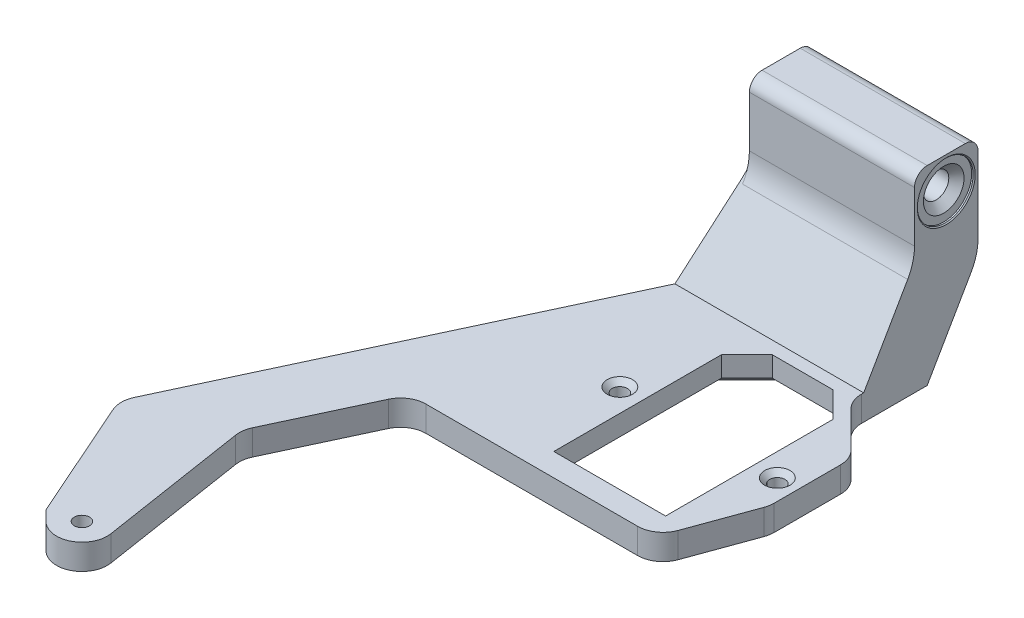
from build123d import *

# Parameters (mm, degrees)
SKETCH1_R           = 6.35
SKETCH1_R_2         = 1.905
BOSS_EXTRUDE1_DEPTH = 6.35
SKETCH2_W           = 41.275
SKETCH2_H           = 15.875
BOSS_EXTRUDE2_DEPTH = 41.275
SKETCH3_R           = 3.175
CUT_EXTRUDE1_DEPTH  = 92.391901083
SKETCH4_R           = 6.985
CUT_EXTRUDE2_DEPTH  = 0.635
CHAMFER1_SIZE       = 0.254
CHAMFER2_SIZE       = 1.905
FILLET3_R           = 3.175
CHAMFER3_SIZE       = 12.7
CHAMFER3_SIZE2      = 21.997045256
SKETCH6_R           = 1.905
CUT_EXTRUDE3_DEPTH  = 6.35
FILLET4_R           = 6.35
CHAMFER4_SIZE       = 1.27
CHAMFER5_SIZE       = 12.7
CHAMFER5_SIZE2      = 21.997045256
FILLET5_R           = 12.7
CHAMFER6_SIZE       = 1.27
SKETCH7_W           = 1.211538461
SKETCH7_H           = 0.583333334
CUT_EXTRUDE4_DEPTH  = 1.27


with BuildPart() as part:
    # Sketch1 → Boss-Extrude1 (new body)
    with BuildSketch(Plane(origin=(0, 0, 0), x_dir=(1, 0, 0), z_dir=(0, 1, 0))):
        with BuildLine():
            Line((-50.116901083, -123.351041208), (-35.638114305, -156.082441816))
            Line((-35.638114305, -156.082441816), (-33.084178049, -158.636378072))
            ThreePointArc((-33.084178049, -158.636378072), (-31.470087933, -148.484898058), (-22.319859515, -153.167968981))
            Line((-22.319859515, -153.167968981), (-28.38020679, -114.3))
            Line((-28.38020679, -114.3), (-15.055465459, -85.725))
            Line((-15.055465459, -85.725), (46.355, -85.725))
            Line((46.355, -85.725), (53.975, -64.789222064))
            Line((53.975, -64.789222064), (53.975, -44.45))
            Line((53.975, -44.45), (41.275, -31.75))
            Line((41.275, -31.75), (41.275, 0))
            Line((41.275, 0), (0, 0))
            Line((0, 0), (0, -15.875))
            Line((0, -15.875), (-50.116901083, -123.351041208))
        make_face()
        with Locations((-28.59405, -154.14625)):
            Circle(SKETCH1_R)
        with Locations((-28.59405, -154.14625)):
            Circle(SKETCH1_R_2, mode=Mode.SUBTRACT)
    extrude(amount=BOSS_EXTRUDE1_DEPTH)

    # Sketch2 → Boss-Extrude2 (add)
    with BuildSketch(Plane(origin=(0, 6.35, 0), x_dir=(1, 0, 0), z_dir=(0, 1, 0))):
        with Locations((20.6375, -7.9375)):
            Rectangle(SKETCH2_W, SKETCH2_H)
    extrude(amount=BOSS_EXTRUDE2_DEPTH)

    # Sketch3 → Cut-Extrude1 (cut, through all)
    with BuildSketch(Plane(origin=(41.275, 0, 0), x_dir=(0, 0, -1), z_dir=(1, 0, 0))):
        with Locations((-7.9375, 39.6875)):
            Circle(SKETCH3_R)
    extrude(amount=-CUT_EXTRUDE1_DEPTH, mode=Mode.SUBTRACT)

    # Sketch4 → Cut-Extrude2 (cut)
    with BuildSketch(Plane(origin=(41.275, 0, 0), x_dir=(0, 0, -1), z_dir=(1, 0, 0))):
        with Locations((-7.9375, 39.6875)):
            Circle(SKETCH4_R)
    cut_extrude2 = extrude(amount=-CUT_EXTRUDE2_DEPTH, mode=Mode.SUBTRACT)

    # Mirror1: Cut-Extrude2 across plane
    add(cut_extrude2.mirror(Plane(origin=(20.6375, 0, 0), x_dir=(0, 0, 1), z_dir=(1, 0, 0))), mode=Mode.SUBTRACT)

    # Chamfer1
    chamfer1_edges = [part.edges().sort_by_distance(p)[0] for p in [
        (41.275, 39.6875, 14.9225),
        (0, 39.6875, 14.9225),
    ]]
    chamfer(chamfer1_edges, length=CHAMFER1_SIZE)

    # Chamfer2
    chamfer2_edges = [part.edges().sort_by_distance(p)[0] for p in [
        (40.64, 39.6875, 11.1125),
        (0.635, 39.6875, 11.1125),
    ]]
    chamfer(chamfer2_edges, length=CHAMFER2_SIZE)

    # Fillet3
    fillet3_edges = [part.edges().sort_by_distance(p)[0] for p in [
        (20.6375, 47.625, 0),
        (20.6375, 47.625, 15.875),
    ]]
    fillet(fillet3_edges, radius=FILLET3_R)

    # Chamfer3
    chamfer3_edges = [part.edges().sort_by_distance(p)[0] for p in [
        (20.6375, 6.35, 15.875),
    ]]
    chamfer3_side = [part.faces().sort_by_distance(p)[0] for p in [
        (4.787320439, 6.35, 69.69475797),
    ]]
    chamfer(chamfer3_edges, length=CHAMFER3_SIZE, length2=CHAMFER3_SIZE2, reference=chamfer3_side[0])

    # Sketch6 → Cut-Extrude3 (cut)
    with BuildSketch(Plane(origin=(0, 6.35, 0), x_dir=(1, 0, 0), z_dir=(0, 1, 0))):
        with Locations((9.525, -57.785)):
            Circle(SKETCH6_R)
        with Locations((48.895, -57.785)):
            Circle(SKETCH6_R)
        Polygon((21.59, -31.75), (36.83, -31.75), (43.18, -38.1), (43.18, -80.01), (15.24, -80.01), (15.24, -38.1), align=None)
    extrude(amount=-CUT_EXTRUDE3_DEPTH, mode=Mode.SUBTRACT)

    # Fillet4
    fillet4_edges = [part.edges().sort_by_distance(p)[0] for p in [
        (-50.116901083, 3.175, 123.351041208),
        (0, 14.173522628, 15.875),
        (41.275, 3.175, 31.75),
        (53.975, 3.175, 44.45),
        (53.975, 3.175, 64.789222064),
        (46.355, 3.175, 85.725),
        (-15.055465459, 3.175, 85.725),
        (-28.38020679, 3.175, 114.3),
    ]]
    fillet(fillet4_edges, radius=FILLET4_R)

    # Chamfer4
    chamfer4_edges = [part.edges().sort_by_distance(p)[0] for p in [
        (46.99, 6.35, 57.785),
        (7.62, 6.35, 57.785),
    ]]
    chamfer(chamfer4_edges, length=CHAMFER4_SIZE)

    # Chamfer5
    chamfer5_edges = [part.edges().sort_by_distance(p)[0] for p in [
        (20.6375, 0, 0),
    ]]
    chamfer5_side = [part.faces().sort_by_distance(p)[0] for p in [
        (0.489673209, 0, 65.243487692),
    ]]
    chamfer(chamfer5_edges, length=CHAMFER5_SIZE, length2=CHAMFER5_SIZE2, reference=chamfer5_side[0])

    # Fillet5
    fillet5_edges = [part.edges().sort_by_distance(p)[0] for p in [
        (20.6375, 28.347045256, 15.875),
        (20.6375, 21.997045256, 0),
    ]]
    fillet(fillet5_edges, radius=FILLET5_R)

    # Chamfer6
    chamfer6_edges = [part.edges().sort_by_distance(p)[0] for p in [
        (29.21, 0, 80.01),
        (15.24, 0, 59.055),
        (40.005, 0, 34.925),
        (43.18, 0, 59.055),
        (18.415, 0, 34.925),
        (29.21, 0, 31.75),
    ]]
    chamfer(chamfer6_edges, length=CHAMFER6_SIZE)

    # Sketch7 → Cut-Extrude4 (cut)
    with BuildSketch(Plane(origin=(0, 5.499261314, 9.525), x_dir=(-1, 0, 0), z_dir=(0, -0.5, -0.866025404))):
        Polygon((-29.044651442, 2.85), (-30.015705128, 2.85), (-30.015705128, 6.35), (-29.3875, 6.35), (-29.3875, 3.433333333), (-28.669551282, 3.433333333), align=None)
        with Locations((-27.256089743, 5.071153846)):
            Rectangle(SKETCH7_W, SKETCH7_H)
        Polygon((-24.496474359, 2.85), (-25.124679487, 2.85), (-25.124679487, 5.721794872), (-26.111858974, 5.721794872), (-26.111858974, 6.35), (-24.496474359, 6.35), align=None)
        Polygon((-21.983653846, 2.85), (-23.868269231, 2.85), (-23.868269231, 3.478205128), (-22.611858974, 3.478205128), (-22.611858974, 4.151282051), (-23.868269231, 4.151282051), (-23.868269231, 4.779487179), (-22.611858974, 4.779487179), (-22.611858974, 5.721794872), (-23.868269231, 5.721794872), (-23.868269231, 6.35), (-21.983653846, 6.35), align=None)
        Polygon((-18.97724359, 2.85), (-19.605448718, 2.85), (-19.605448718, 4.081870994), (-20.598237179, 2.85), (-21.391205929, 2.85), (-20.143910256, 4.398076923), (-21.5125, 6.35), (-20.755989583, 6.35), (-19.605448718, 4.708673878), (-19.605448718, 6.35), (-18.97724359, 6.35), align=None)
        with BuildLine():
            Line((-18.259294872, 3.317648237), (-17.789543269, 3.747435897))
            add(Edge.make_bspline(
                [(-17.789543269, 3.747435897), (-17.769424997, 3.71904645), (-17.730800719, 3.66454267), (-17.668131863, 3.591640495), (-17.605837409, 3.529041531), (-17.542643684, 3.478535555), (-17.479638684, 3.437876653), (-17.415483835, 3.409832569), (-17.350917194, 3.39179725), (-17.307515597, 3.389562353), (-17.286137821, 3.388461538)],
                knots=[0, 0, 0, 0, 0.000104333, 0.000200305, 0.000288057, 0.000368866, 0.00044259, 0.000512284, 0.000578268, 0.000642316, 0.000642316, 0.000642316, 0.000642316], degree=3))
            add(Edge.make_bspline(
                [(-17.286137821, 3.388461538), (-17.266189076, 3.389140004), (-17.227673293, 3.390449941), (-17.173021939, 3.404125845), (-17.123908464, 3.426225369), (-17.08164112, 3.456752335), (-17.047637961, 3.493210391), (-17.021198474, 3.532021771), (-17.005834436, 3.574338955), (-17.00386139, 3.60336082), (-17.002884615, 3.617728365)],
                knots=[0, 0, 0, 0, 5.9744e-05, 0.000115349, 0.000167746, 0.00022048, 0.000270574, 0.000316662, 0.00036057, 0.000403619, 0.000403619, 0.000403619, 0.000403619], degree=3))
            add(Edge.make_bspline(
                [(-17.002884615, 3.617728365), (-17.003502913, 3.632296353), (-17.004748077, 3.661634255), (-17.016774671, 3.704632605), (-17.034902182, 3.746646998), (-17.052223759, 3.772223158), (-17.061077724, 3.785296474)],
                knots=[0, 0, 0, 0, 4.3611e-05, 8.7826e-05, 0.000133031, 0.000180298, 0.000180298, 0.000180298, 0.000180298], degree=3))
            add(Edge.make_bspline(
                [(-17.061077724, 3.785296474), (-17.069159396, 3.795427995), (-17.087869828, 3.818884171), (-17.122462535, 3.856628409), (-17.167694581, 3.900938045), (-17.22165419, 3.954045716), (-17.286366365, 4.013888531), (-17.360441706, 4.082199171), (-17.445528304, 4.156657175), (-17.50514015, 4.20922113), (-17.536438301, 4.23681891)],
                knots=[0, 0, 0, 0, 3.8873e-05, 8.9997e-05, 0.000153455, 0.000228819, 0.000317115, 0.000417855, 0.000531103, 0.000656288, 0.000656288, 0.000656288, 0.000656288], degree=3))
            add(Edge.make_bspline(
                [(-17.536438301, 4.23681891), (-17.565886513, 4.262291824), (-17.6217731, 4.310634123), (-17.701187839, 4.379361089), (-17.771434578, 4.440915553), (-17.831874452, 4.495758452), (-17.884313546, 4.541631288), (-17.926432601, 4.58135622), (-17.960034223, 4.613195453), (-17.979116008, 4.632448406), (-17.987259615, 4.640665064)],
                knots=[0, 0, 0, 0, 0.00011681, 0.000221681, 0.000315075, 0.000396998, 0.000466519, 0.000524062, 0.000570675, 0.000605379, 0.000605379, 0.000605379, 0.000605379], degree=3))
            add(Edge.make_bspline(
                [(-17.987259615, 4.640665064), (-18.018173815, 4.674094588), (-18.077601764, 4.738357872), (-18.154685749, 4.838215347), (-18.218812171, 4.934942996), (-18.26847152, 5.031272249), (-18.304486676, 5.129193842), (-18.330704433, 5.230104872), (-18.346419448, 5.335448168), (-18.348158741, 5.407172142), (-18.349038462, 5.443449519)],
                knots=[0, 0, 0, 0, 0.000136539, 0.000262476, 0.000377989, 0.000484287, 0.00058678, 0.000690342, 0.000796635, 0.00090542, 0.00090542, 0.00090542, 0.00090542], degree=3))
            add(Edge.make_bspline(
                [(-18.349038462, 5.443449519), (-18.348411529, 5.478797664), (-18.347181465, 5.54815204), (-18.332131848, 5.649646549), (-18.310641302, 5.746763182), (-18.277526905, 5.838529029), (-18.236826703, 5.926031588), (-18.187222972, 6.009300286), (-18.126577453, 6.08639113), (-18.059217959, 6.159384245), (-17.983546672, 6.224903173), (-17.902175673, 6.282666563), (-17.814949999, 6.331437639), (-17.722534374, 6.371630033), (-17.623769756, 6.401457226), (-17.520216388, 6.424008321), (-17.41083093, 6.437605566), (-17.336189859, 6.439020647), (-17.298056891, 6.43974359)],
                knots=[0, 0, 0, 0, 0.000105953, 0.000207884, 0.000307206, 0.000403889, 0.000499869, 0.000596423, 0.000693889, 0.000793598, 0.000893984, 0.000993583, 0.001092463, 0.001193271, 0.001295284, 0.001401448, 0.001510935, 0.001625295, 0.001625295, 0.001625295, 0.001625295], degree=3))
            add(Edge.make_bspline(
                [(-17.298056891, 6.43974359), (-17.268122396, 6.439213111), (-17.208834929, 6.438162459), (-17.121458292, 6.429567137), (-17.03707046, 6.415738924), (-16.955839981, 6.395766284), (-16.877253023, 6.371036783), (-16.802162428, 6.338879594), (-16.729569821, 6.302514065), (-16.659716612, 6.260372306), (-16.593181641, 6.211428743), (-16.528047911, 6.157615149), (-16.466624477, 6.095980077), (-16.406564518, 6.028770457), (-16.350376434, 5.954038394), (-16.295099415, 5.874032643), (-16.243431374, 5.786840619), (-16.21150142, 5.725687022), (-16.195192308, 5.694451122)],
                knots=[0, 0, 0, 0, 8.9787e-05, 0.000177831, 0.000263126, 0.00034611, 0.000428593, 0.000509977, 0.000590874, 0.000672038, 0.000754359, 0.000838473, 0.000925234, 0.001015134, 0.001108667, 0.001205513, 0.001306757, 0.001412461, 0.001412461, 0.001412461, 0.001412461], degree=3))
            Line((-16.195192308, 5.694451122), (-16.747676282, 5.362820513))
            add(Edge.make_bspline(
                [(-16.747676282, 5.362820513), (-16.768075093, 5.398278527), (-16.807181356, 5.46625457), (-16.873450575, 5.557588999), (-16.941340007, 5.635801818), (-17.012419195, 5.699510612), (-17.085823842, 5.749567249), (-17.161908509, 5.785341194), (-17.240726653, 5.807485226), (-17.294413992, 5.810189524), (-17.32119391, 5.811538462)],
                knots=[0, 0, 0, 0, 0.000122646, 0.000235123, 0.000337949, 0.000432798, 0.000520693, 0.0006035, 0.000684117, 0.000764351, 0.000764351, 0.000764351, 0.000764351], degree=3))
            add(Edge.make_bspline(
                [(-17.32119391, 5.811538462), (-17.348437937, 5.810447314), (-17.401295318, 5.808330329), (-17.47686667, 5.788390474), (-17.546457004, 5.757785427), (-17.606287018, 5.713275092), (-17.657094202, 5.662520363), (-17.693517732, 5.605277022), (-17.717144403, 5.544084598), (-17.719598875, 5.501383871), (-17.720833333, 5.479907853)],
                knots=[0, 0, 0, 0, 8.1575e-05, 0.000158267, 0.000232945, 0.000308256, 0.000380645, 0.000447163, 0.000510598, 0.000574784, 0.000574784, 0.000574784, 0.000574784], degree=3))
            add(Edge.make_bspline(
                [(-17.720833333, 5.479907853), (-17.719677845, 5.45993794), (-17.71733058, 5.419370973), (-17.700135446, 5.359019401), (-17.673028636, 5.298960471), (-17.641920387, 5.24917714), (-17.609488362, 5.207680663), (-17.577698765, 5.172266476), (-17.540022594, 5.132321373), (-17.49549984, 5.088934614), (-17.444996462, 5.04127201), (-17.388347124, 4.989446883), (-17.324941764, 4.933881685), (-17.28012493, 4.896032766), (-17.256690705, 4.876241987)],
                knots=[0, 0, 0, 0, 5.9859e-05, 0.000121597, 0.000186877, 0.000257108, 0.000297078, 0.000344765, 0.000399815, 0.000461788, 0.000531224, 0.000608146, 0.000692108, 0.000784127, 0.000784127, 0.000784127, 0.000784127], degree=3))
            add(Edge.make_bspline(
                [(-17.256690705, 4.876241987), (-17.212142979, 4.838547865), (-17.126642408, 4.766201434), (-17.00579768, 4.659369191), (-16.89698157, 4.559450315), (-16.800919799, 4.465645445), (-16.717327015, 4.378553937), (-16.64528298, 4.298940369), (-16.585951887, 4.225243531), (-16.524429184, 4.137221382), (-16.4643197, 4.031473183), (-16.413235193, 3.90364819), (-16.380220124, 3.775983241), (-16.37650704, 3.69013197), (-16.374679487, 3.647876603)],
                knots=[0, 0, 0, 0, 0.000175062, 0.000335996, 0.000483855, 0.000618216, 0.000738713, 0.000845964, 0.000940241, 0.00102232, 0.001167987, 0.00130391, 0.001434509, 0.001561092, 0.001561092, 0.001561092, 0.001561092], degree=3))
            add(Edge.make_bspline(
                [(-16.374679487, 3.647876603), (-16.37543992, 3.61791207), (-16.376938056, 3.558878721), (-16.390262085, 3.472068605), (-16.410267963, 3.388343727), (-16.439017647, 3.307725272), (-16.477578848, 3.231121447), (-16.52312669, 3.157292402), (-16.576958134, 3.086463794), (-16.638654685, 3.020206812), (-16.706380517, 2.959299982), (-16.778616703, 2.905863883), (-16.854695841, 2.860678487), (-16.93484864, 2.823867878), (-17.018933269, 2.795142752), (-17.107027392, 2.774842241), (-17.198861044, 2.762736248), (-17.26132814, 2.761093321), (-17.293149038, 2.76025641)],
                knots=[0, 0, 0, 0, 8.9842e-05, 0.000176999, 0.000262874, 0.000347814, 0.0004331, 0.000519683, 0.000607745, 0.000699528, 0.000790884, 0.00088063, 0.000968648, 0.001055861, 0.001144771, 0.001234739, 0.001326661, 0.001422106, 0.001422106, 0.001422106, 0.001422106], degree=3))
            add(Edge.make_bspline(
                [(-17.293149038, 2.76025641), (-17.334384905, 2.761769014), (-17.416531136, 2.764782282), (-17.538022656, 2.788222158), (-17.65674892, 2.825472728), (-17.752717044, 2.869352226), (-17.82842015, 2.913213437), (-17.886580551, 2.952775989), (-17.946223419, 2.998207372), (-18.006253815, 3.050829675), (-18.068948106, 3.107600998), (-18.131139561, 3.172417353), (-18.195873611, 3.241957734), (-18.237784104, 3.291976076), (-18.259294872, 3.317648237)],
                knots=[0, 0, 0, 0, 0.000123638, 0.0002463, 0.000369811, 0.000496249, 0.000561908, 0.000632107, 0.000707131, 0.000786676, 0.000871524, 0.000960767, 0.001056037, 0.001156496, 0.001156496, 0.001156496, 0.001156496], degree=3))
        make_face()
        with BuildLine():
            Line((-15.836217949, 3.457171474), (-15.375580929, 3.897475962))
            add(Edge.make_bspline(
                [(-15.375580929, 3.897475962), (-15.336551427, 3.857013471), (-15.260190478, 3.777848892), (-15.136559163, 3.674213837), (-15.009461098, 3.586137048), (-14.878540537, 3.514348203), (-14.74387269, 3.457375999), (-14.605223258, 3.417632214), (-14.462927152, 3.392607174), (-14.366769814, 3.389851096), (-14.318289263, 3.388461538)],
                knots=[0, 0, 0, 0, 0.000168561, 0.000329789, 0.000483038, 0.000631768, 0.000776955, 0.000920741, 0.001063668, 0.001209005, 0.001209005, 0.001209005, 0.001209005], degree=3))
            add(Edge.make_bspline(
                [(-14.318289263, 3.388461538), (-14.277807491, 3.389580861), (-14.197921176, 3.391789722), (-14.080638213, 3.408021871), (-13.968408463, 3.43552123), (-13.861142882, 3.473745138), (-13.758311141, 3.521881855), (-13.660870783, 3.582386238), (-13.568298156, 3.653238881), (-13.481674892, 3.734315798), (-13.403472823, 3.823553761), (-13.333011647, 3.917537333), (-13.274649146, 4.017928856), (-13.227007901, 4.123264314), (-13.189465505, 4.233581743), (-13.16282016, 4.348875622), (-13.147381829, 4.469406264), (-13.145080076, 4.55134507), (-13.143910256, 4.592988782)],
                knots=[0, 0, 0, 0, 0.000121424, 0.000239616, 0.000354399, 0.000467495, 0.000580715, 0.000694351, 0.000810883, 0.000929933, 0.001049644, 0.001166454, 0.001281773, 0.001397244, 0.001512759, 0.001630789, 0.001751669, 0.001876594, 0.001876594, 0.001876594, 0.001876594], degree=3))
            add(Edge.make_bspline(
                [(-13.143910256, 4.592988782), (-13.144252198, 4.622216395), (-13.144926171, 4.679824621), (-13.152117861, 4.764824227), (-13.16406152, 4.847472276), (-13.180813446, 4.927523892), (-13.201902695, 5.005324398), (-13.227713928, 5.080367041), (-13.258922188, 5.152748101), (-13.293849415, 5.22284673), (-13.332835662, 5.290068951), (-13.376537456, 5.353523328), (-13.424465088, 5.412716795), (-13.4747008, 5.469709077), (-13.530571594, 5.5211649), (-13.589575938, 5.569920069), (-13.65256043, 5.614766743), (-13.719448581, 5.65508082), (-13.788243858, 5.692652839), (-13.860355981, 5.723767312), (-13.933769855, 5.751737369), (-14.009773407, 5.772779269), (-14.087027838, 5.791081273), (-14.166608457, 5.802258876), (-14.247760015, 5.810752376), (-14.302607261, 5.811275305), (-14.330208333, 5.811538462)],
                knots=[0, 0, 0, 0, 8.7665e-05, 0.00017279, 0.000255683, 0.000338049, 0.000417989, 0.000497368, 0.000575897, 0.000654285, 0.000732207, 0.000808832, 0.000885151, 0.000960612, 0.001036505, 0.001112721, 0.00119015, 0.001268189, 0.001346921, 0.001425086, 0.001503617, 0.001582396, 0.001661486, 0.001741605, 0.0018233, 0.001906059, 0.001906059, 0.001906059, 0.001906059], degree=3))
            add(Edge.make_bspline(
                [(-14.330208333, 5.811538462), (-14.377025312, 5.81018736), (-14.4690085, 5.807532798), (-14.603987161, 5.786683869), (-14.732978674, 5.752542905), (-14.835840145, 5.711478019), (-14.916324358, 5.671557084), (-14.977564333, 5.635159944), (-15.040623754, 5.593932242), (-15.105070873, 5.546731906), (-15.171254548, 5.494120641), (-15.238037797, 5.434998807), (-15.307121108, 5.371298037), (-15.352377262, 5.325834193), (-15.375580929, 5.302524038)],
                knots=[0, 0, 0, 0, 0.0001404, 0.000275849, 0.000408674, 0.000539911, 0.000607324, 0.00067803, 0.000753481, 0.000833277, 0.000917589, 0.001007026, 0.00110079, 0.001199449, 0.001199449, 0.001199449, 0.001199449], degree=3))
            Line((-15.375580929, 5.302524038), (-15.822195513, 5.771574519))
            add(Edge.make_bspline(
                [(-15.822195513, 5.771574519), (-15.790800912, 5.801885022), (-15.729525365, 5.861044642), (-15.637092897, 5.945045762), (-15.544776783, 6.020530181), (-15.454807079, 6.090237307), (-15.365710371, 6.152137589), (-15.277494781, 6.206288708), (-15.191163562, 6.254074721), (-15.104907794, 6.294639408), (-15.018042773, 6.329302868), (-14.928705464, 6.358536317), (-14.83685318, 6.384055114), (-14.741725198, 6.404137091), (-14.643745968, 6.42048521), (-14.54260065, 6.431287688), (-14.438761826, 6.438778526), (-14.368550173, 6.439419276), (-14.333012821, 6.43974359)],
                knots=[0, 0, 0, 0, 0.000130917, 0.000255521, 0.000374557, 0.000488566, 0.000596896, 0.00069983, 0.000798983, 0.000892761, 0.00098559, 0.001079375, 0.001174627, 0.001271438, 0.001370911, 0.001472494, 0.001576496, 0.001683088, 0.001683088, 0.001683088, 0.001683088], degree=3))
            add(Edge.make_bspline(
                [(-14.333012821, 6.43974359), (-14.267737623, 6.438076654), (-14.140012205, 6.434814924), (-13.95281589, 6.41073091), (-13.774836882, 6.370087909), (-13.605755379, 6.313388381), (-13.446088841, 6.239764346), (-13.295336552, 6.15043004), (-13.153749559, 6.044537582), (-13.022546206, 5.923664673), (-12.903903716, 5.790142608), (-12.798918947, 5.646831478), (-12.712457499, 5.49270213), (-12.639099404, 5.331056111), (-12.584128655, 5.159366273), (-12.544114795, 4.97918403), (-12.519766569, 4.789736159), (-12.517076885, 4.660369077), (-12.515705128, 4.594391026)],
                knots=[0, 0, 0, 0, 0.000195794, 0.000383114, 0.000565099, 0.000742694, 0.00091712, 0.001091592, 0.001267434, 0.00144656, 0.001625835, 0.00180254, 0.001978381, 0.00215507, 0.00233422, 0.002518103, 0.002708205, 0.002906072, 0.002906072, 0.002906072, 0.002906072], degree=3))
            add(Edge.make_bspline(
                [(-12.515705128, 4.594391026), (-12.516304238, 4.551362534), (-12.517491527, 4.466090581), (-12.529196219, 4.340152341), (-12.547151728, 4.217894618), (-12.572706634, 4.09946778), (-12.604480767, 3.984461778), (-12.644924643, 3.873397325), (-12.691769037, 3.765666413), (-12.746459362, 3.662273006), (-12.807764296, 3.563086445), (-12.874787168, 3.468357441), (-12.94881862, 3.379028221), (-13.029155147, 3.294708083), (-13.115129074, 3.214852042), (-13.207581222, 3.140026843), (-13.306599992, 3.070715015), (-13.41117536, 3.006859593), (-13.51931644, 2.948217203), (-13.631100086, 2.899045704), (-13.744347853, 2.855639195), (-13.859827055, 2.82057881), (-13.977791866, 2.794132675), (-14.09734148, 2.774175571), (-14.219452698, 2.76300602), (-14.301441253, 2.761178786), (-14.342828526, 2.76025641)],
                knots=[0, 0, 0, 0, 0.000129054, 0.000255754, 0.000379103, 0.000499566, 0.000618987, 0.000736753, 0.000853859, 0.000971154, 0.001087316, 0.001203459, 0.001318993, 0.001435041, 0.001552623, 0.001670772, 0.001791564, 0.001914938, 0.002038212, 0.002160299, 0.00228101, 0.00240189, 0.002521971, 0.002643459, 0.002765271, 0.002889441, 0.002889441, 0.002889441, 0.002889441], degree=3))
            add(Edge.make_bspline(
                [(-14.342828526, 2.76025641), (-14.378135845, 2.760785803), (-14.448383387, 2.761839085), (-14.552996647, 2.770603817), (-14.656761808, 2.784407821), (-14.759362002, 2.805089586), (-14.861258618, 2.830136155), (-14.962025041, 2.860986767), (-15.061383405, 2.898617282), (-15.160195069, 2.940244574), (-15.25648938, 2.987635084), (-15.349429476, 3.040679474), (-15.439245646, 3.097990053), (-15.525396448, 3.16055257), (-15.608488679, 3.227448064), (-15.688433681, 3.29867432), (-15.764464321, 3.375523365), (-15.812179158, 3.42981785), (-15.836217949, 3.457171474)],
                knots=[0, 0, 0, 0, 0.000105907, 0.000210712, 0.000314726, 0.000419778, 0.000524527, 0.000629426, 0.000735694, 0.00084313, 0.000950994, 0.001057437, 0.001164017, 0.001270463, 0.001376675, 0.001483927, 0.001591509, 0.00170074, 0.00170074, 0.00170074, 0.00170074], degree=3))
        make_face()
        Polygon((-10.541346154, 2.85), (-11.169551282, 2.85), (-11.169551282, 5.721794872), (-12.156730769, 5.721794872), (-12.156730769, 6.35), (-10.541346154, 6.35), align=None)
    extrude(amount=-CUT_EXTRUDE4_DEPTH, mode=Mode.SUBTRACT)


solid = part.part
